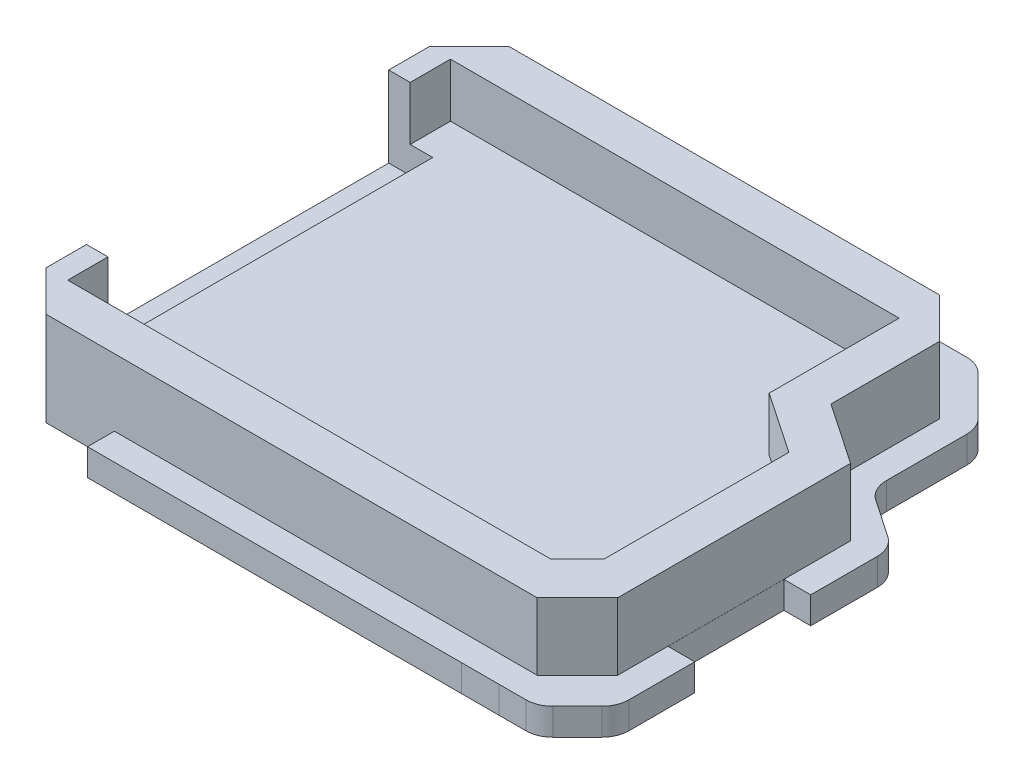
from build123d import *

# Parameters (mm, degrees)
SKETCH1_W               = 41
SKETCH1_H               = 34.5
SKETCH1_W_2             = 35
SKETCH1_H_2             = 28.5
BOSS_EXTRUDE1_DEPTH     = 5
SKETCH2_W               = 35
SKETCH2_H               = 28.5
BOSS_EXTRUDE2_DEPTH     = 1
SKETCH6_W               = 34.5
SKETCH6_H               = 5
CUT_EXTRUDE2_DEPTH      = 3
SKETCH7_W               = 1.6
SKETCH7_H               = 3
BOSS_EXTRUDE3_DEPTH     = 4
CHAMFER1_SIZE           = 3
SKETCH14_W              = 3.502632447
SKETCH14_H              = 20.452559449
CUT_EXTRUDE6_DEPTH      = 10
BOSS_EXTRUDE5_DEPTH     = 4
BOSS_EXTRUDE7_DEPTH     = 1
SKETCH9_W               = 3.28281374
SKETCH9_H               = 22.420706044
CUT_EXTRUDE3_DEPTH      = 4
BOSS_EXTRUDE4_DEPTH     = 2
SKETCH12_W              = 3.28281374
SKETCH12_H              = 22.420706044
CUT_EXTRUDE4_DEPTH      = 1
BOSS_EXTRUDE8_DEPTH     = 2
BOSS_EXTRUDE9_DEPTH     = 2
CUT_EXTRUDE7_DEPTH      = 1
CUT_EXTRUDE7_DEPTH_BACK = 4
CHAMFER2_SIZE           = 3
CHAMFER2_EDGE_2_SIZE2   = 3
CHAMFER2_EDGE_2_SIZE    = 3.001586398
CHAMFER3_SIZE           = 2
CUT_EXTRUDE8_DEPTH      = 10
SKETCH29_W              = 2.811538377
SKETCH29_H              = 2
CUT_EXTRUDE9_DEPTH      = 10
SKETCH31_W              = 5.26
SKETCH31_H              = 2
CUT_EXTRUDE10_DEPTH     = 10
SKETCH33_W              = 1.99335007
SKETCH33_H              = 8.633384354
CUT_EXTRUDE11_DEPTH     = 10
FILLET1_R               = 2


with BuildPart() as part:
    # Sketch1 → Boss-Extrude1 (new body)
    with BuildSketch(Plane(origin=(0, 0, 0), x_dir=(1, 0, 0), z_dir=(0, 1, 0))):
        with Locations((-14.14154724, 0.334775681)):
            Rectangle(SKETCH1_W, SKETCH1_H)
        with Locations((-14.14154724, 0.334775681)):
            Rectangle(SKETCH1_W_2, SKETCH1_H_2, mode=Mode.SUBTRACT)
    extrude(amount=BOSS_EXTRUDE1_DEPTH)

    # Sketch2 → Boss-Extrude2 (add)
    with BuildSketch(Plane(origin=(0, 0, 0), x_dir=(1, 0, 0), z_dir=(0, 1, 0))):
        with Locations((-14.14154724, 0.334775681)):
            Rectangle(SKETCH2_W, SKETCH2_H)
    extrude(amount=BOSS_EXTRUDE2_DEPTH)

    # Sketch6 → Cut-Extrude2 (cut)
    with BuildSketch(Plane.ZY.offset(34.64154724)):
        with Locations((-0.334775681, 2.5)):
            Rectangle(SKETCH6_W, SKETCH6_H)
    extrude(amount=-CUT_EXTRUDE2_DEPTH, mode=Mode.SUBTRACT)

    # Sketch7 → Boss-Extrude3 (add)
    with BuildSketch(Plane(origin=(0, 1, 0), x_dir=(1, 0, 0), z_dir=(0, 1, 0))):
        with Locations((-30.84154724, 13.084775681)):
            Rectangle(SKETCH7_W, SKETCH7_H)
        with Locations((-30.84154724, -12.415224319)):
            Rectangle(SKETCH7_W, SKETCH7_H)
    extrude(amount=BOSS_EXTRUDE3_DEPTH)

    # Chamfer1
    chamfer1_edges = [part.edges().sort_by_distance(p)[0] for p in [
        (-31.64154724, 2.5, -17.584775681),
        (-31.64154724, 2.5, 16.915224319),
        (6.35845276, 2.5, -17.584775681),
        (6.35845276, 2.5, 16.915224319),
    ]]
    chamfer(chamfer1_edges, length=CHAMFER1_SIZE)

    # Sketch14 → Cut-Extrude6 (cut)
    with BuildSketch(Plane(origin=(0, 1, 0), x_dir=(1, 0, 0), z_dir=(0, 1, 0))):
        with Locations((5.109768984, -7.134544415)):
            Rectangle(SKETCH14_W, SKETCH14_H)
    extrude(amount=CUT_EXTRUDE6_DEPTH, mode=Mode.SUBTRACT)

    # Sketch17 → Boss-Extrude5 (add)
    with BuildSketch(Plane(origin=(0, 1, 0), x_dir=(1, 0, 0), z_dir=(0, 1, 0))):
        Polygon((3.35845276, 3.09173531), (7.910000942, 0), (7.910000942, -13.915224319), (3.35845276, -13.915224319), (3.35845276, -16.915224319), (10.910000942, -16.915224319), (10.910000942, 3.419581668), (3.35845276, 8.549130391), align=None)
    extrude(amount=BOSS_EXTRUDE5_DEPTH)

    # Sketch19 → Boss-Extrude7 (add)
    with BuildSketch(Plane.XZ):
        Polygon((3.35845276, 16.915224319), (10.910000942, 16.915224319), (10.910000942, -3.419581668), (6.35845276, -6.511316978), (6.35845276, 13.915224319), align=None)
    extrude(amount=-BOSS_EXTRUDE7_DEPTH)

    # Sketch9 → Cut-Extrude3 (cut)
    with BuildSketch(Plane(origin=(0, 1, 0), x_dir=(1, 0, 0), z_dir=(0, 1, 0))):
        with Locations((-30.00014037, 0.374422659)):
            Rectangle(SKETCH9_W, SKETCH9_H)
    extrude(amount=-CUT_EXTRUDE3_DEPTH, mode=Mode.SUBTRACT)

    # Sketch11 → Boss-Extrude4 (add)
    with BuildSketch(Plane.XZ):
        Polygon((-26.665503706, 18.915224319), (-31.64154724, 13.915224319), (-31.64154724, -14.584775681), (-26.629189212, -19.584775681), (4.233785533, -19.584775681), (8.35845276, -15.460108453), (8.35845276, 14.743651444), (4.263960312, 18.915224319), align=None)
    extrude(amount=BOSS_EXTRUDE4_DEPTH)

    # Sketch12 → Cut-Extrude4 (cut)
    with BuildSketch(Plane(origin=(0, 0, 0), x_dir=(1, 0, 0), z_dir=(0, 1, 0))):
        with Locations((-30.00014037, 0.374422659)):
            Rectangle(SKETCH12_W, SKETCH12_H)
    extrude(amount=-CUT_EXTRUDE4_DEPTH, mode=Mode.SUBTRACT)

    # Sketch20 → Boss-Extrude8 (add)
    with BuildSketch(Plane.XZ):
        Polygon((6.227005221, 16.915224319), (10.910000942, 16.915224319), (10.910000942, -3.419581668), (8.35845276, -5.152774704), (8.35845276, 14.743651444), align=None)
    extrude(amount=BOSS_EXTRUDE8_DEPTH)

    # Sketch21 → Boss-Extrude9 (add)
    with BuildSketch(Plane(origin=(0, 0, 0), x_dir=(1, 0, 0), z_dir=(0, 1, 0))):
        Polygon((8.35845276, 7.570549944), (8.35845276, 5.152774704), (10.90766939, 3.421165424), (10.90766939, -16.912751148), (6.227005221, -16.915224319), (4.263960312, -18.915224319), (7.06681334, -18.91478086), (12.90766939, -18.911694666), (12.90766939, 4.480398389), align=None)
    extrude(amount=-BOSS_EXTRUDE9_DEPTH)

    # Sketch23 → Cut-Extrude7 (cut, two sides)
    with BuildSketch(Plane(origin=(0, 5, 0), x_dir=(1, 0, 0), z_dir=(0, 1, 0))) as cut_extrude7_sk:
        Polygon((7.910000942, 0), (7.910000942, 1.828776855), (3.35845276, 4.913740582), (3.35845276, 3.09173531), align=None)
    extrude(amount=CUT_EXTRUDE7_DEPTH, mode=Mode.SUBTRACT)
    extrude(cut_extrude7_sk.sketch, amount=-CUT_EXTRUDE7_DEPTH_BACK, mode=Mode.SUBTRACT)

    # Chamfer2
    chamfer2_edges = [part.edges().sort_by_distance(p)[0] for p in [
        (10.910000942, 2.5, 16.915224319),
    ]]
    chamfer(chamfer2_edges, length=CHAMFER2_SIZE)

    # Chamfer2 edge 2
    chamfer2_edge_2_edges = [part.edges().sort_by_distance(p)[0] for p in [
        (12.90766939, -1, 18.911694666),
    ]]
    chamfer(chamfer2_edge_2_edges, length=CHAMFER2_EDGE_2_SIZE, length2=CHAMFER2_EDGE_2_SIZE2)

    # Chamfer3
    chamfer3_edges = [part.edges().sort_by_distance(p)[0] for p in [
        (7.910000942, 3, 13.915224319),
    ]]
    chamfer(chamfer3_edges, length=CHAMFER3_SIZE)

    # Sketch27 → Cut-Extrude8 (cut)
    with BuildSketch(Plane(origin=(0, 0, 0), x_dir=(1, 0, 0), z_dir=(0, 1, 0))):
        Polygon((-23.564566169, -18.915224319), (-23.564566169, -16.956730787), (-23.564566169, -16.915224319), (-28.64154724, -16.915224319), (-26.665503706, -18.915224319), align=None)
    extrude(amount=-CUT_EXTRUDE8_DEPTH, mode=Mode.SUBTRACT)

    # Sketch29 → Cut-Extrude9 (cut)
    with BuildSketch(Plane(origin=(-22.95033658, 0, 22.675432092), x_dir=(-0.702833562, 0, -0.711354331), z_dir=(0.711354331, 0, -0.702833562))):
        with Locations((6.691753419, -1)):
            Rectangle(SKETCH29_W, SKETCH29_H)
    extrude(amount=-CUT_EXTRUDE9_DEPTH, mode=Mode.SUBTRACT)

    # Sketch31 → Cut-Extrude10 (cut)
    with BuildSketch(Plane(origin=(0, 0, 0), x_dir=(1, 0, 0), z_dir=(0, 1, 0))):
        with Locations((-26.164712617, 18.586994213)):
            Rectangle(SKETCH31_W, SKETCH31_H)
    extrude(amount=-CUT_EXTRUDE10_DEPTH, mode=Mode.SUBTRACT)

    # Sketch33 → Cut-Extrude11 (cut)
    with BuildSketch(Plane.XZ.offset(2)):
        with Locations((11.910994355, 5.861564698)):
            Rectangle(SKETCH33_W, SKETCH33_H)
    extrude(amount=-CUT_EXTRUDE11_DEPTH, mode=Mode.SUBTRACT)

    # Fillet1
    fillet1_edges = [part.edges().sort_by_distance(p)[0] for p in [
        (4.233785533, -1, -19.584775681),
        (8.35845276, -1, -15.460108453),
        (8.35845276, -1, -7.570549944),
        (12.90766939, -1, -4.480398389),
        (9.906083411, -1, 18.913280645),
        (12.90766939, -1, 15.911694666),
    ]]
    fillet(fillet1_edges, radius=FILLET1_R)


solid = part.part
